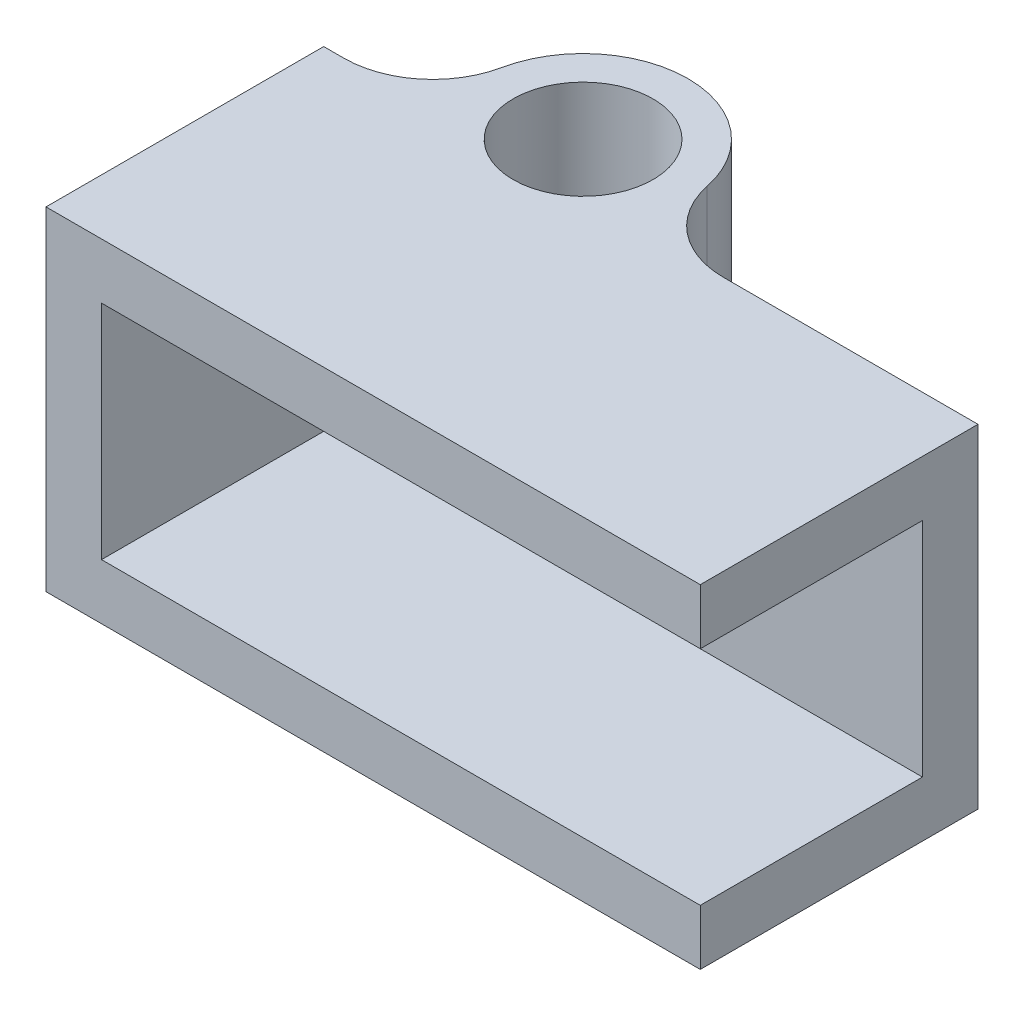
from build123d import *

# Parameters (mm, degrees)
SKETCH1_R           = 2
BOSS_EXTRUDE1_DEPTH = 9.525
FILLET1_R           = 2.54
BOSS_EXTRUDE2_DEPTH = 6.35


with BuildPart() as part:
    # Sketch1 → Boss-Extrude1 (new body)
    with BuildSketch(Plane(origin=(0, 0, 0), x_dir=(1, 0, 0), z_dir=(0, 1, 0))):
        with BuildLine():
            Line((-6, -1.4125), (-6, -3))
            Line((-6, -3), (12.7, -3))
            Line((12.7, -3), (12.7, -1.4125))
            Line((12.7, -1.4125), (2.646666535, -1.4125))
            ThreePointArc((2.646666535, -1.4125), (0, 3), (-2.646666535, -1.4125))
            Line((-2.646666535, -1.4125), (-6, -1.4125))
        make_face()
        Circle(SKETCH1_R, mode=Mode.SUBTRACT)
    extrude(amount=BOSS_EXTRUDE1_DEPTH)

    # Fillet1
    fillet1_edges = [part.edges().sort_by_distance(p)[0] for p in [
        (-2.646666535, 4.7625, 1.4125),
        (2.646666535, 4.7625, 1.4125),
    ]]
    fillet(fillet1_edges, radius=FILLET1_R)

    # Sketch2 → Boss-Extrude2 (add)
    with BuildSketch(Plane.XY.offset(3)):
        Polygon((12.7, 0), (-6, 0), (-6, 9.525), (12.7, 9.525), (12.7, 7.9375), (-4.4125, 7.9375), (-4.4125, 1.5875), (12.7, 1.5875), align=None)
    extrude(amount=BOSS_EXTRUDE2_DEPTH)


solid = part.part
